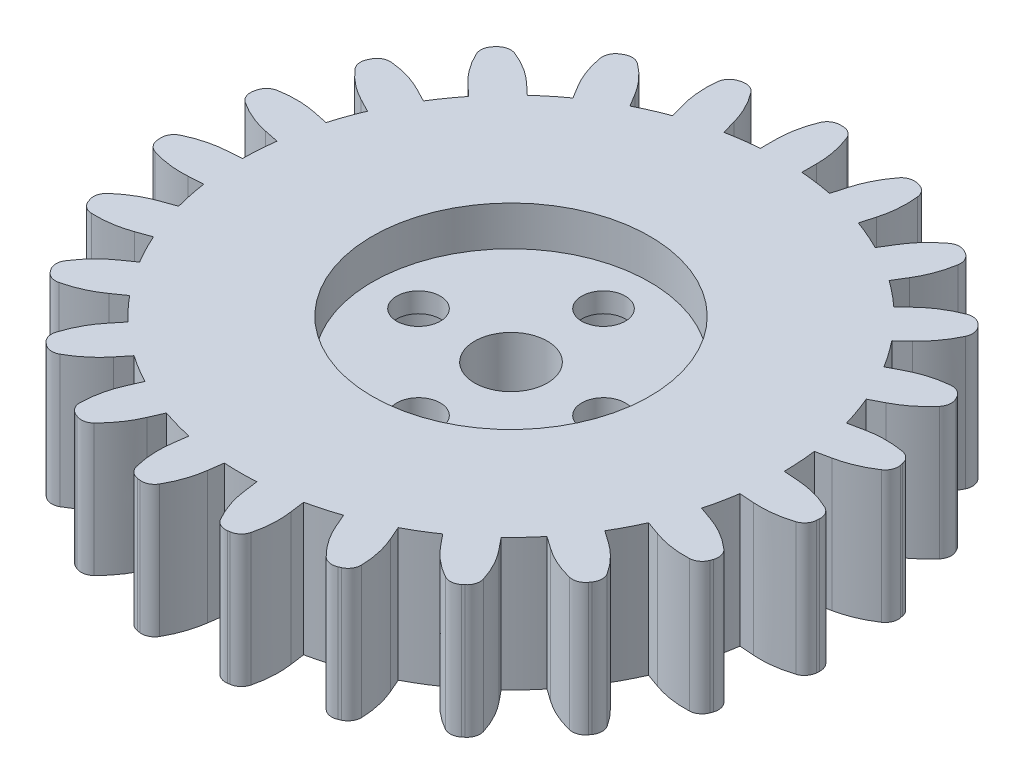
from build123d import *

# Parameters (mm, degrees)
BOSS_EXTRU_2_DEPTH                 = 10
CONG_1_R                           = 1
R_P_TITION_CIRCULAIRE1_COUNT       = 23
CONG_1_OF_R_P_TITION_CIRCULAIRE1_R = 1
ESQUISSE2_R                        = 10.5
ENL_V_MAT_EXTRU_1_DEPTH            = 3
ESQUISSE3_R                        = 2.75
ESQUISSE3_R_2                      = 1.65
ENL_V_MAT_EXTRU_2_DEPTH            = 8.0000001
ESQUISSE4_R                        = 2.75
ENL_V_MAT_EXTRU_3_DEPTH            = 5.5


with BuildPart() as part:
    # Esquisse1 → Boss.-Extru.2 (new body)
    with BuildSketch(Plane(origin=(0, 0, 0), x_dir=(1, 0, 0), z_dir=(0, 1, 0))):
        with BuildLine():
            add(Edge.make_bspline(
                [(0.74, 24.9890456), (1.568599657, 23.362544157), (1.57, 21.557906322)],
                knots=[0, 0, 0, 1, 1, 1], degree=2))
            Line((1.57, 21.557906322), (1.57, 20.439792073))
            ThreePointArc((1.57, 20.439792073), (2.922533102, 20.290608672), (4.262189662, 20.052025815))
            Line((4.262189662, 20.052025815), (0, 0))
            Line((0, 0), (-4.262189662, 20.052025815))
            ThreePointArc((-4.262189662, 20.052025815), (-2.922533102, 20.290608672), (-1.57, 20.439792073))
            Line((-1.57, 20.439792073), (-1.57, 21.557906322))
            add(Edge.make_bspline(
                [(-0.74, 24.9890456), (-1.568599657, 23.362544157), (-1.57, 21.557906322)],
                knots=[0, 0, 0, 1, 1, 1], degree=2))
            ThreePointArc((-0.74, 24.9890456), (0, 25), (0.74, 24.9890456))
        make_face()
    boss_extru_2 = extrude(amount=BOSS_EXTRU_2_DEPTH)

    # Congé1
    cong_1_edges = [part.edges().sort_by_distance(p)[0] for p in [
        (0.74, 5, -24.9890456),
        (-0.74, 5, -24.9890456),
    ]]
    fillet(cong_1_edges, radius=CONG_1_R)

    # Répétition circulaire1: Boss.-Extru.2 ×23 about axis
    r_p_tition_circulaire1_axis = Axis((0, 10, 0), (0, -1, 0))
    for i in range(1, R_P_TITION_CIRCULAIRE1_COUNT):
        add(boss_extru_2.rotate(r_p_tition_circulaire1_axis, i * 360 / R_P_TITION_CIRCULAIRE1_COUNT))

    # Congé1 of Répétition circulaire1
    cong_1_of_r_p_tition_circulaire1_edges = [part.edges().sort_by_distance(p)[0] for p in [
        (7.45452261, 5, -23.862734392),
        (6.029405025, 5, -24.262033613),
        (13.61617738, 5, -20.966633339),
        (12.351636661, 5, -21.735617585),
        (18.767982563, 5, -16.515533007),
        (17.757803912, 5, -17.597170234),
        (22.527852338, 5, -10.839551145),
        (21.846956082, 5, -12.153621268),
        (24.616934363, 5, -4.359649363),
        (24.315819464, 5, -5.808693813),
        (24.880290981, 5, 2.443587669),
        (24.981289753, 5, 0.96703789),
        (23.298390237, 5, 9.065594981),
        (23.794012063, 5, 7.671048817),
        (19.988554472, 5, 15.015248587),
        (20.842041349, 5, 13.806133145),
        (15.196259063, 5, 19.851289895),
        (16.344311774, 5, 18.917279737),
        (9.276926638, 5, 23.215051845),
        (10.634399364, 5, 22.625418232),
        (2.669567003, 5, 24.857059601),
        (4.135782204, 5, 24.65553296),
        (-4.135782204, 5, 24.65553296),
        (-2.669567003, 5, 24.857059601),
        (-10.634399364, 5, 22.625418232),
        (-9.276926638, 5, 23.215051845),
        (-16.344311774, 5, 18.917279737),
        (-15.196259063, 5, 19.851289895),
        (-20.842041349, 5, 13.806133145),
        (-19.988554472, 5, 15.015248587),
        (-23.794012063, 5, 7.671048817),
        (-23.298390237, 5, 9.065594981),
        (-24.981289753, 5, 0.96703789),
        (-24.880290981, 5, 2.443587669),
        (-24.315819464, 5, -5.808693813),
        (-24.616934363, 5, -4.359649363),
        (-21.846956082, 5, -12.153621268),
        (-22.527852338, 5, -10.839551145),
        (-17.757803912, 5, -17.597170234),
        (-18.767982563, 5, -16.515533007),
        (-12.351636661, 5, -21.735617585),
        (-13.61617738, 5, -20.966633339),
        (-6.029405025, 5, -24.262033613),
        (-7.45452261, 5, -23.862734392),
    ]]
    fillet(cong_1_of_r_p_tition_circulaire1_edges, radius=CONG_1_OF_R_P_TITION_CIRCULAIRE1_R)

    # Esquisse2 → Enlèv. mat.-Extru.1 (cut)
    with BuildSketch(Plane(origin=(0, 10, 0), x_dir=(1, 0, 0), z_dir=(0, 1, 0))):
        Circle(ESQUISSE2_R)
    extrude(amount=-ENL_V_MAT_EXTRU_1_DEPTH, mode=Mode.SUBTRACT)

    # Esquisse3 → Enlèv. mat.-Extru.2 (cut, through all)
    with BuildSketch(Plane(origin=(0, 7, 0), x_dir=(1, 0, 0), z_dir=(0, 1, 0))):
        Circle(ESQUISSE3_R)
        with Locations((0, 7)):
            Circle(ESQUISSE3_R_2)
        with Locations((7, 0)):
            Circle(ESQUISSE3_R_2)
        with Locations((0, -7)):
            Circle(ESQUISSE3_R_2)
        with Locations((-7, 0)):
            Circle(ESQUISSE3_R_2)
    extrude(amount=-ENL_V_MAT_EXTRU_2_DEPTH, mode=Mode.SUBTRACT)

    # Esquisse4 → Enlèv. mat.-Extru.3 (cut)
    with BuildSketch(Plane.XZ):
        with Locations((0, 7)):
            Circle(ESQUISSE4_R)
        with Locations((7, 0)):
            Circle(ESQUISSE4_R)
        with Locations((0, -7)):
            Circle(ESQUISSE4_R)
        with Locations((-7, 0)):
            Circle(ESQUISSE4_R)
    extrude(amount=-ENL_V_MAT_EXTRU_3_DEPTH, mode=Mode.SUBTRACT)


solid = part.part
